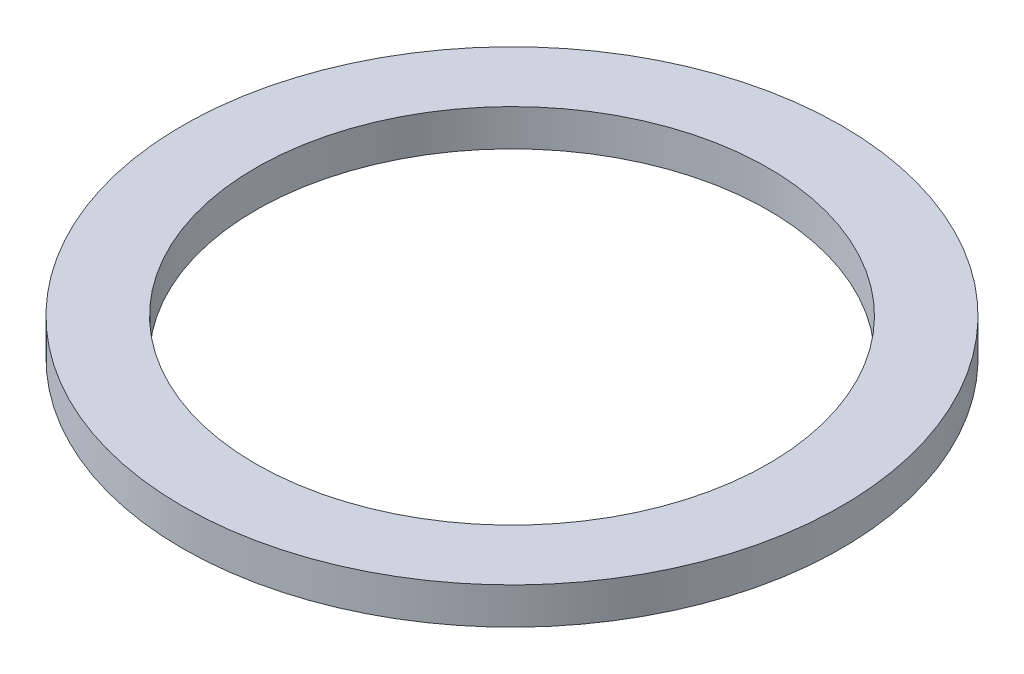
from build123d import *

# Parameters (mm, degrees)
CROQUIS1_R              = 45
CROQUIS1_R_2            = 35
SALIENTE_EXTRUIR1_DEPTH = 5


with BuildPart() as part:
    # Croquis1 → Saliente-Extruir1 (new body)
    with BuildSketch(Plane(origin=(0, 0, 0), x_dir=(1, 0, 0), z_dir=(0, 1, 0))):
        Circle(CROQUIS1_R)
        Circle(CROQUIS1_R_2, mode=Mode.SUBTRACT)
    extrude(amount=SALIENTE_EXTRUIR1_DEPTH)


solid = part.part
